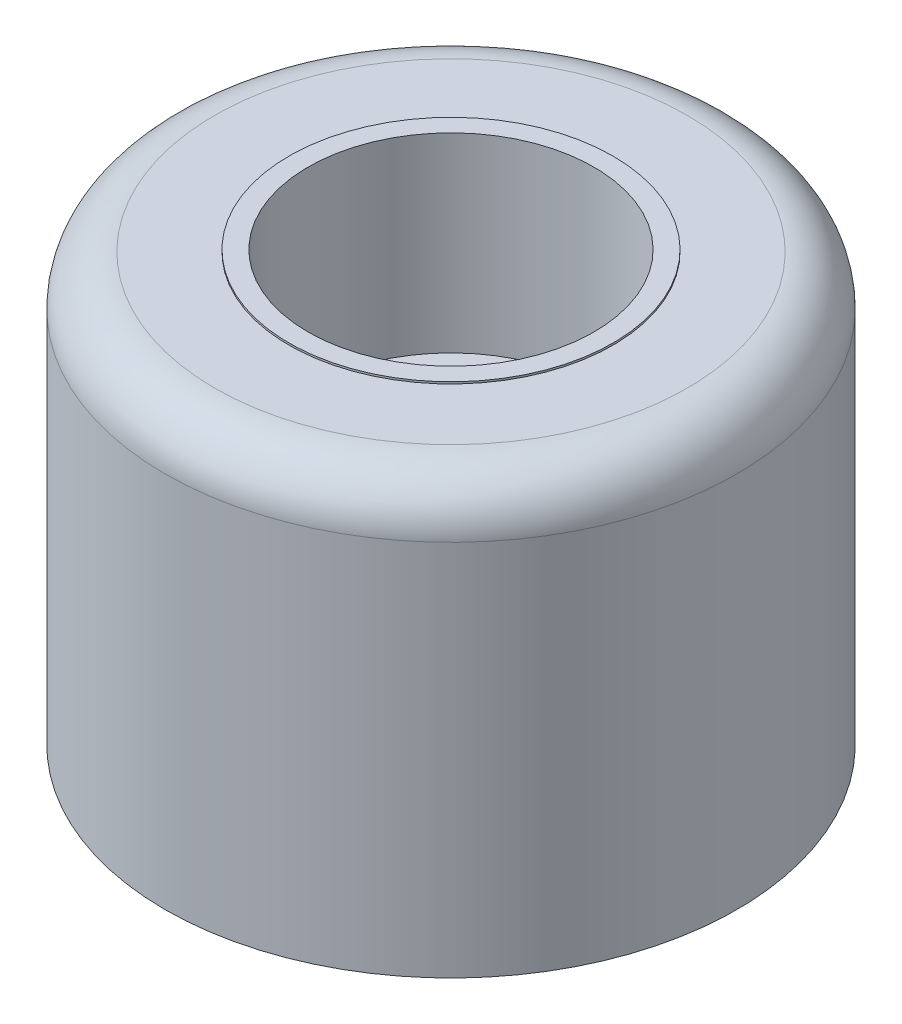
from build123d import *

# Parameters (mm, degrees)
SKETCH3_R                = 9.525
SKETCH3_R_2              = 2.38125
BOSS_EXTRUDE1_DEPTH      = 6.35
BOSS_EXTRUDE1_DEPTH_BACK = 7.9375
SKETCH4_R                = 4.7625
CUT_EXTRUDE1_DEPTH       = 6.35
SKETCH5_W                = 4.1275
SKETCH5_H                = 0.0635
FILLET2_R                = 1.651


with BuildPart() as part:
    # Sketch3 → Boss-Extrude1 (new body, two sides)
    with BuildSketch(Plane(origin=(0, 0, 0), x_dir=(1, 0, 0), z_dir=(0, 1, 0))) as boss_extrude1_sk:
        Circle(SKETCH3_R)
        Circle(SKETCH3_R_2, mode=Mode.SUBTRACT)
    extrude(amount=BOSS_EXTRUDE1_DEPTH)
    extrude(boss_extrude1_sk.sketch, amount=-BOSS_EXTRUDE1_DEPTH_BACK)

    # Sketch4 → Cut-Extrude1 (cut)
    with BuildSketch(Plane(origin=(0, 0, 0), x_dir=(1, 0, 0), z_dir=(0, 1, 0))):
        Circle(SKETCH4_R)
    extrude(amount=CUT_EXTRUDE1_DEPTH, mode=Mode.SUBTRACT)

    # Sketch5 → Cut-Revolve1 (revolve, cut)
    with BuildSketch(Plane.XY):
        with Locations((-7.46125, 6.31825)):
            Rectangle(SKETCH5_W, SKETCH5_H)
    revolve(axis=Axis((0, -7.9375, 0), (0, 1, 0)), mode=Mode.SUBTRACT)

    # Fillet2
    fillet2_edges = [part.edges().sort_by_distance(p)[0] for p in [
        (-9.525, 6.2865, 0),
    ]]
    fillet(fillet2_edges, radius=FILLET2_R)


solid = part.part
